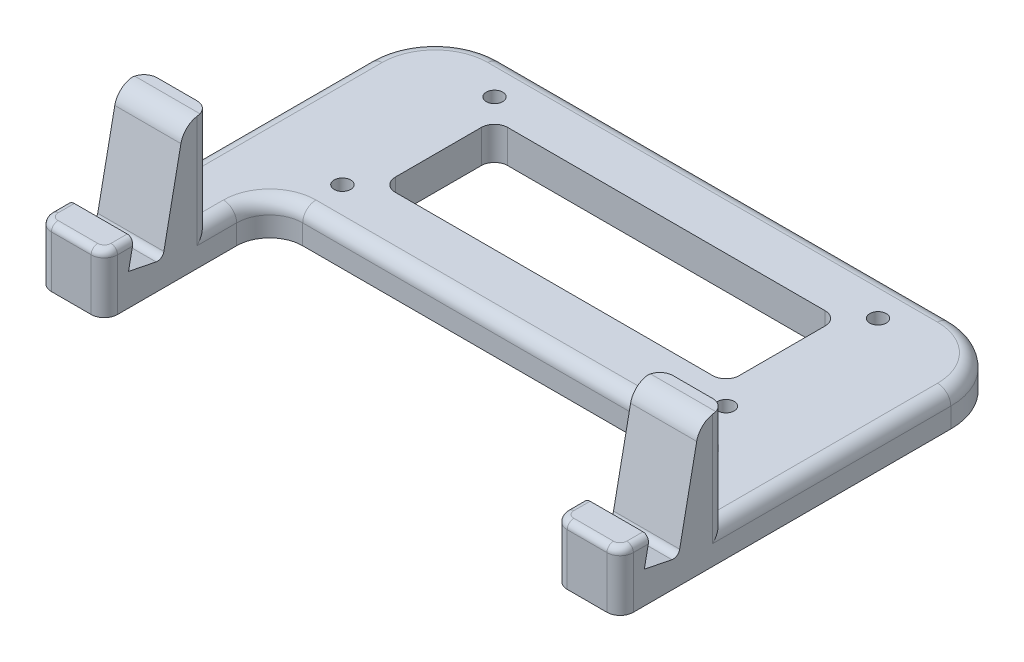
from build123d import *

# Parameters (mm, degrees)
SKETCH1_R           = 1.2500000000000062
SKETCH1_R_2         = 1.2500000000000029
SKETCH1_R_3         = 1.2499999999999978
SKETCH1_R_4         = 1.2499999999999976
BOSS_EXTRUDE1_DEPTH = 5
BOSS_EXTRUDE2_DEPTH = 20
CUT_EXTRUDE1_DEPTH  = 109.36973747315251
FILLET1_R           = 1
FILLET4_R           = 2
FILLET5_R           = 2
FILLET8_R           = 3
FILLET9_R           = 1


with BuildPart() as part:
    # Sketch1 → Boss-Extrude1 (new body)
    with BuildSketch(Plane(origin=(0, 0, 0), x_dir=(1, 0, 0), z_dir=(0, 1, 0))):
        with BuildLine():
            Line((78, -39.99999999999999), (78, -46))
            ThreePointArc((78, -46), (78.5857864376269, -44.58578643762691), (79.99999999999999, -43.99999999999999))
            Line((79.99999999999999, -44), (85.99999999999999, -44))
            ThreePointArc((85.99999999999999, -44), (87.41421356237308, -44.58578643762691), (87.99999999999999, -46))
            Line((87.99999999999999, -46), (88, -9.999999999999998))
            ThreePointArc((88, -9.999999999999998), (85.07106781186548, -2.9289321881345147), (77.99999999999999, -5.33e-15))
            Line((77.99999999999999, 0), (10.000000000000071, 0))
            ThreePointArc((10.000000000000071, 1.78e-15), (2.9289321881345236, -2.9289321881345245), (0, -10.000000000000071))
            Line((1.22e-15, -10.000000000000071), (5.63e-15, -46))
            ThreePointArc((4.88e-15, -46), (0.5857864376269124, -44.58578643762691), (2.000000000000006, -44))
            Line((2.000000000000006, -44), (8.000000000000005, -44))
            ThreePointArc((8.000000000000005, -44), (9.414213562373103, -44.5857864376269), (10.000000000000007, -46))
            Line((10.000000000000007, -46), (10.000000000000007, -39.99999999999999))
            ThreePointArc((10.000000000000007, -39.99999999999999), (11.46446609406727, -36.464466094067255), (15.000000000000007, -34.99999999999999))
            Line((15.000000000000007, -34.99999999999999), (73, -34.99999999999999))
            ThreePointArc((73, -34.99999999999999), (76.53553390593274, -36.464466094067255), (78, -39.99999999999999))
        make_face()
        with Locations((15.000000000000002, -28.999999999999996)):
            Circle(SKETCH1_R, mode=Mode.SUBTRACT)
        with Locations((14.999999999999998, -6)):
            Circle(SKETCH1_R_2, mode=Mode.SUBTRACT)
        with BuildLine():
            ThreePointArc((17.999999999999996, -11.000000000000004), (18.5857864376269, -9.585786437626908), (19.999999999999996, -9))
            Line((19.999999999999996, -9), (68, -9))
            ThreePointArc((68, -9.000000000000005), (69.41421356237309, -9.58578643762691), (70, -11.000000000000004))
            Line((70, -11.000000000000004), (70, -24))
            ThreePointArc((70, -24), (69.41421356237309, -25.414213562373092), (68, -25.999999999999996))
            Line((68, -26.000000000000004), (19.999999999999996, -26))
            ThreePointArc((19.999999999999996, -26), (18.585786437626908, -25.41421356237309), (18.000000000000004, -24))
            Line((18.000000000000004, -24), (17.999999999999996, -11.000000000000004))
        make_face(mode=Mode.SUBTRACT)
        with Locations((73.00000000000001, -28.999999999999993)):
            Circle(SKETCH1_R_3, mode=Mode.SUBTRACT)
        with Locations((73.00000000000001, -6)):
            Circle(SKETCH1_R_4, mode=Mode.SUBTRACT)
    extrude(amount=BOSS_EXTRUDE1_DEPTH)

    # Sketch1_3 → Boss-Extrude2 (add)
    with BuildSketch(Plane(origin=(0, 0, 0), x_dir=(1, 0, 0), z_dir=(0, 1, 0))):
        with BuildLine():
            ThreePointArc((78, -57.99999999999999), (78.5857864376269, -59.41421356237309), (80, -60))
            Line((80, -60), (86, -60))
            ThreePointArc((86, -60), (87.41421356237309, -59.4142135623731), (87.99999999999999, -57.99999999999999))
            Line((87.99999999999999, -57.99999999999999), (87.99999999999999, -46))
            ThreePointArc((87.99999999999999, -46), (87.41421356237308, -44.58578643762691), (85.99999999999999, -44))
            Line((85.99999999999999, -44), (79.99999999999999, -44))
            ThreePointArc((79.99999999999999, -43.99999999999999), (78.5857864376269, -44.58578643762691), (78, -46))
            Line((78, -46), (78, -57.99999999999999))
        make_face()
        with BuildLine():
            Line((10.000000000000007, -57.99999999999998), (10.000000000000007, -46))
            ThreePointArc((10.000000000000007, -46), (9.414213562373103, -44.5857864376269), (8.000000000000005, -44))
            Line((8.000000000000005, -44), (2.000000000000006, -44))
            ThreePointArc((2.000000000000006, -44), (0.5857864376269124, -44.58578643762691), (4.88e-15, -46))
            Line((5.63e-15, -46), (7.1e-15, -57.99999999999998))
            ThreePointArc((7.99e-15, -57.99999999999998), (0.5857864376269144, -59.414213562373085), (2.0000000000000218, -60))
            Line((2.0000000000000218, -60), (7.999999999999993, -60))
            ThreePointArc((7.999999999999993, -60), (9.4142135623731, -59.414213562373085), (10.000000000000007, -57.99999999999998))
        make_face()
    extrude(amount=BOSS_EXTRUDE2_DEPTH)

    # Sketch2 → Cut-Extrude1 (cut, through all)
    with BuildSketch(Plane(origin=(88, 0, 2.544e-14), x_dir=(-2.9e-16, 0, -1), z_dir=(1, 0, -2.9e-16))):
        Polygon((-60.00000000000003, 20), (-59.99999999999998, 8.816905616081954), (-55.53957096656065, 8.816905616081954), (-56.34341854385401, 4.816905616081951), (-51.19632430540917, 3.782535807663335), (-47.93723198019628, 20), align=None)
    extrude(amount=-CUT_EXTRUDE1_DEPTH, mode=Mode.SUBTRACT)

    # Fillet1
    fillet1_edges = [part.edges().sort_by_distance(p)[0] for p in [
        (1.038e-14, 8.816905616081954, 56.769785483280344),
        (10.00000000000001, 8.816905616081954, 56.76978548328034),
        (9.4142135623731, 8.816905616081954, 59.414213562373085),
        (5.000000000000014, 8.816905616081954, 60.00000000000003),
        (0.585786437626916, 8.816905616081954, 59.414213562373085),
        (78, 8.816905616081954, 56.76978548328034),
        (78.5857864376269, 8.816905616081954, 59.4142135623731),
        (88.00000000000001, 8.816905616081954, 56.76978548328034),
        (87.41421356237309, 8.816905616081954, 59.41421356237309),
        (83, 8.816905616081954, 60.00000000000001),
    ]]
    fillet(fillet1_edges, radius=FILLET1_R)

    # Fillet4
    fillet4_edges = [part.edges().sort_by_distance(p)[0] for p in [
        (88, 5, 28),
        (85.07106781186548, 5, 2.928932188134512),
        (44.00000000000003, 5, 0),
        (2.9289321881345245, 5, 2.9289321881345236),
        (3.43e-15, 5, 28.000000000000036),
    ]]
    fillet(fillet4_edges, radius=FILLET4_R)

    # Fillet5
    fillet5_edges = [part.edges().sort_by_distance(p)[0] for p in [
        (10.000000000000007, 5, 43),
        (11.46446609406727, 5, 36.464466094067255),
        (78, 5, 43),
        (76.53553390593274, 5, 36.464466094067255),
        (44, 5, 34.99999999999999),
    ]]
    fillet(fillet5_edges, radius=FILLET5_R)

    # Fillet8
    fillet8_edges = [part.edges().sort_by_distance(p)[0] for p in [
        (83, 20, 47.93723198019631),
        (5.000000000000014, 20, 47.93723198019633),
    ]]
    fillet(fillet8_edges, radius=FILLET8_R)

    # Fillet9
    fillet9_edges = [part.edges().sort_by_distance(p)[0] for p in [
        (83, 3.782535807663335, 51.1963243054092),
        (5.000000000000014, 3.782535807663335, 51.19632430540922),
    ]]
    fillet(fillet9_edges, radius=FILLET9_R)


solid = part.part
